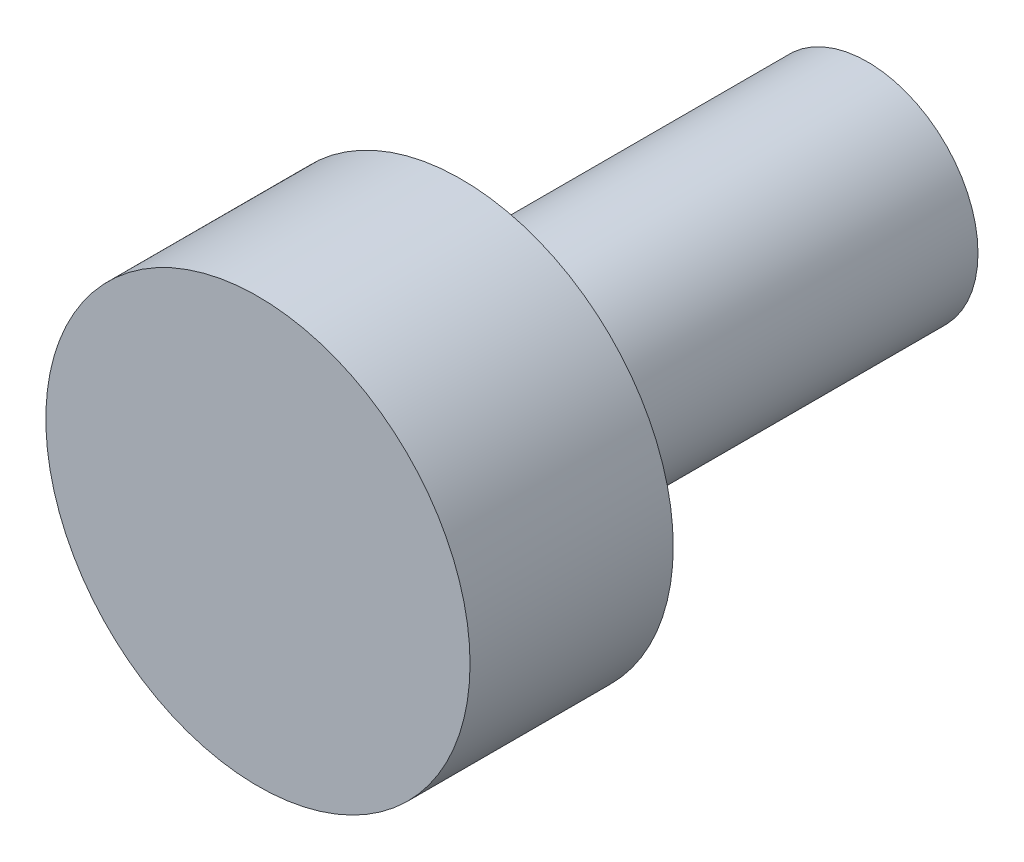
from build123d import *

# Parameters (mm, degrees)
SKETCH1_R           = 1.7272
BOSS_EXTRUDE1_DEPTH = 6.35
SKETCH2_R           = 3.3147
BOSS_EXTRUDE2_DEPTH = 3.175


with BuildPart() as part:
    # Sketch1 → Boss-Extrude1 (new body)
    with BuildSketch(Plane.XY):
        Circle(SKETCH1_R)
    extrude(amount=BOSS_EXTRUDE1_DEPTH)

    # Sketch2 → Boss-Extrude2 (add)
    with BuildSketch(Plane.XY.offset(6.35)):
        Circle(SKETCH2_R)
    extrude(amount=BOSS_EXTRUDE2_DEPTH)


solid = part.part
